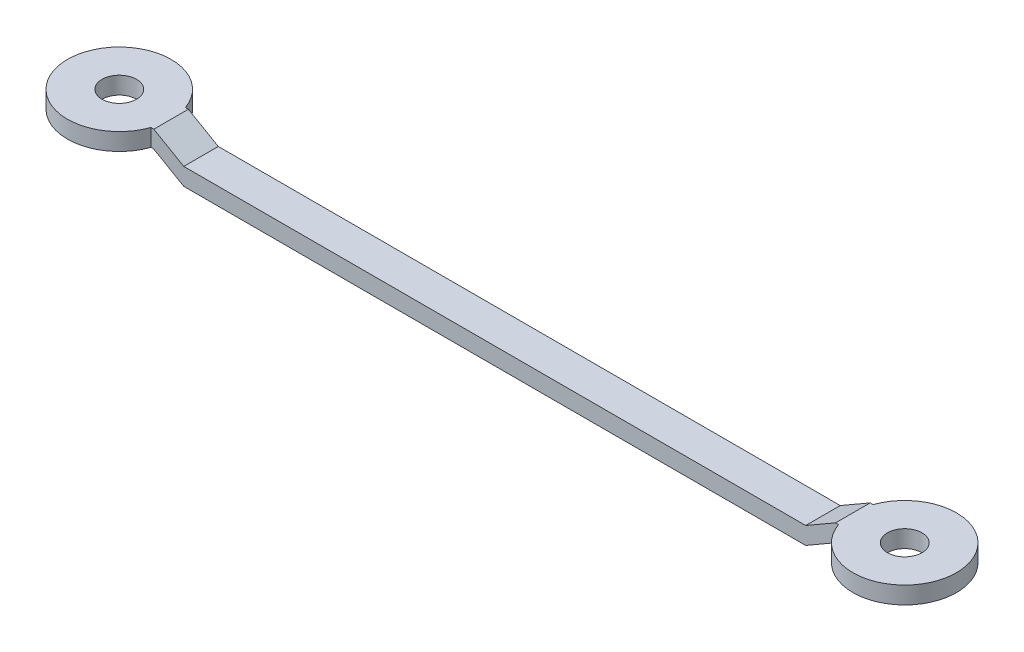
from build123d import *

# Parameters (mm, degrees)
BOSS_EXTRUDE1_DEPTH     = 2
SKETCH3_R               = 3
BOSS_EXTRUDE2_DEPTH     = 1
SKETCH4_R               = 3
BOSS_EXTRUDE3_DEPTH     = 1
SKETCH5_R               = 1
CUT_EXTRUDE5_DEPTH      = 1
CUT_EXTRUDE5_DEPTH_BACK = 3


with BuildPart() as part:
    # Sketch2 → Boss-Extrude1 (new body)
    with BuildSketch(Plane.XY):
        Polygon((-18, 0), (18, 0), (19.732050808, 1), (20.970146046, 1), (20.970146046, 2), (19.732050808, 2), (18, 1), (-18, 1), (-19.732050808, 2), (-20.970146046, 2), (-20.970146046, 1), (-19.732050808, 1), align=None)
    extrude(amount=BOSS_EXTRUDE1_DEPTH)

    # Sketch3 → Boss-Extrude2 (add)
    with BuildSketch(Plane(origin=(0, 2, 0), x_dir=(1, 0, 0), z_dir=(0, 1, 0))):
        with Locations((-22.732050808, -1)):
            Circle(SKETCH3_R)
    extrude(amount=-BOSS_EXTRUDE2_DEPTH)

    # Sketch4 → Boss-Extrude3 (add)
    with BuildSketch(Plane(origin=(0, 2, 0), x_dir=(1, 0, 0), z_dir=(0, 1, 0))):
        with Locations((22.732050808, -1)):
            Circle(SKETCH4_R)
    extrude(amount=-BOSS_EXTRUDE3_DEPTH)

    # Sketch5 → Cut-Extrude5 (cut, two sides)
    with BuildSketch(Plane(origin=(0, 2, 0), x_dir=(1, 0, 0), z_dir=(0, 1, 0))) as cut_extrude5_sk:
        with Locations((-22.732050808, -1)):
            Circle(SKETCH5_R)
        with Locations((22.732050808, -1)):
            Circle(SKETCH5_R)
    extrude(amount=CUT_EXTRUDE5_DEPTH, mode=Mode.SUBTRACT)
    extrude(cut_extrude5_sk.sketch, amount=-CUT_EXTRUDE5_DEPTH_BACK, mode=Mode.SUBTRACT)


solid = part.part
